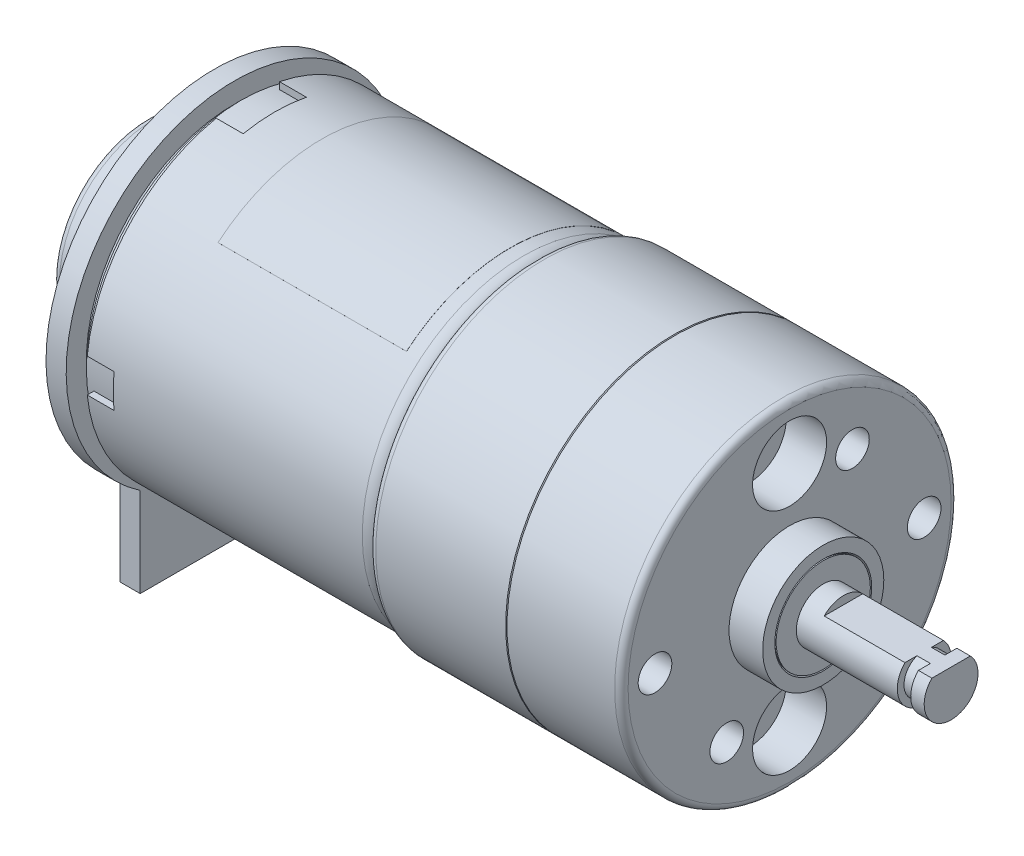
from build123d import *

# Parameters (mm, degrees)
ESQUISSE3_W                = 4.7
ESQUISSE3_H                = 3
ESQUISSE3_W_2              = 3
ESQUISSE3_H_2              = 2.5
ENL_V_MAT_EXTRU_1_DEPTH    = 2
CHANFREIN1_SIZE            = 0.5
ESQUISSE5_R                = 1.25
BOSS_EXTRU_1_DEPTH         = 1.5
ESQUISSE6_R                = 12.5
BOSS_EXTRU_2_DEPTH         = 10.25
CONG_2_R                   = 0.5
CHANFREIN2_SIZE            = 0.1
ESQUISSE7_R                = 12.5
BOSS_EXTRU_3_DEPTH         = 8.5
CONG_3_R                   = 0.5
ESQUISSE8_R                = 4.5
ESQUISSE8_R_2              = 3.5
BOSS_EXTRU_4_DEPTH         = 2.5
CHANFREIN3_SIZE            = 0.1
ESQUISSE10_R               = 3.5
ESQUISSE10_R_2             = 2
BOSS_EXTRU_6_DEPTH         = 2.5
ESQUISSE13_W               = 11.559263521
ESQUISSE13_H               = 4.088991178
ENL_V_MAT_EXTRU_2_DEPTH    = 8
ESQUISSE14_R               = 1
BOSS_EXTRU_8_DEPTH         = 7.5
ESQUISSE16_R               = 7
ESQUISSE16_R_2             = 3.5
BOSS_EXTRU_9_DEPTH         = 4
CONG_4_R                   = 0.5
ESQUISSE17_R               = 3.5
ESQUISSE17_R_2             = 1.005
BOSS_EXTRU_10_DEPTH        = 0.1
BOSS_EXTRU_10_DEPTH_BACK   = 4.1
ESQUISSE18_R               = 2.75
ENL_V_MAT_EXTRU_3_DEPTH    = 3
TROU_TARAUD_M32_AT_2_COUNT = 2
TROU_TARAUD_M32_AT_2_PITCH = 17
BOSS_EXTRU_11_DEPTH        = 14


with BuildPart() as part:
    # Esquisse1 → Révol.-Mince3 (revolve)
    with BuildSketch(Plane.XY):
        with BuildLine():
            Line((0, 0), (0, -11))
            ThreePointArc((0, -11), (-0.292893219, -11.707106781), (-1, -12))
            Line((-1, -12), (-21.5, -12))
            Line((-21.5, -12), (-21.5, -11.5))
            Line((-21.5, -11.5), (-1, -11.5))
            ThreePointArc((-1, -11.5), (-0.646446609, -11.353553391), (-0.5, -11))
            Line((-0.5, -11), (-0.5, 0))
            Line((-0.5, 0), (0, 0))
        make_face()
    revolve(axis=Axis((-41.566699443, 0, 0), (1, 0, 0)))

    # Esquisse3 → Enlèv. mat.-Extru.1 (cut)
    with BuildSketch(Plane.ZY.offset(21.5)):
        with Locations((0, -11.5)):
            Rectangle(ESQUISSE3_W, ESQUISSE3_H)
        with Locations((0, 11.5)):
            Rectangle(ESQUISSE3_W, ESQUISSE3_H)
        with Locations((11.5, 0)):
            Rectangle(ESQUISSE3_W_2, ESQUISSE3_H_2)
        with Locations((-11.5, 0)):
            Rectangle(ESQUISSE3_W_2, ESQUISSE3_H_2)
    extrude(amount=-ENL_V_MAT_EXTRU_1_DEPTH, mode=Mode.SUBTRACT)

    # Esquisse4 → Révolution2 (revolve)
    with BuildSketch(Plane.XY):
        with BuildLine():
            Line((-0.5, 11), (-0.5, 0))
            Line((-0.5, 0), (-22.5, 0))
            Line((-22.5, 0), (-22.5, 11.5))
            Line((-22.5, 11.5), (-1, 11.5))
            ThreePointArc((-1, 11.5), (-0.646446609, 11.353553391), (-0.5, 11))
        make_face()
    revolve(axis=Axis((-25.268401873, 0, 0), (1, 0, 0)))

    # Chanfrein1
    chanfrein1_edges = [part.edges().sort_by_distance(p)[0] for p in [
        (-22.5, -11.5, 0),
    ]]
    chamfer(chanfrein1_edges, length=CHANFREIN1_SIZE)

    # Esquisse5 → Boss.-Extru.1 (add)
    with BuildSketch(Plane.ZY.offset(22.5)):
        with BuildLine():
            Line((-7, -10.356157589), (-7, -17))
            Line((-7, -17), (7, -17))
            Line((7, -17), (7, -10.356157589))
            ThreePointArc((7, -10.356157589), (0, 12.5), (-7, -10.356157589))
        make_face()
        Circle(ESQUISSE5_R, mode=Mode.SUBTRACT)
    extrude(amount=BOSS_EXTRU_1_DEPTH)

    # Esquisse6 → Boss.-Extru.2 (add)
    with BuildSketch(Plane(origin=(0, 0, 0), x_dir=(0, 0, -1), z_dir=(1, 0, 0))):
        Circle(ESQUISSE6_R)
    extrude(amount=BOSS_EXTRU_2_DEPTH)

    # Congé2
    cong_2_edges = [part.edges().sort_by_distance(p)[0] for p in [
        (0, 0, 12.5),
    ]]
    fillet(cong_2_edges, radius=CONG_2_R)

    # Chanfrein2
    chanfrein2_edges = [part.edges().sort_by_distance(p)[0] for p in [
        (10.25, 0, 12.5),
    ]]
    chamfer(chanfrein2_edges, length=CHANFREIN2_SIZE)

    # Esquisse7 → Boss.-Extru.3 (add)
    with BuildSketch(Plane(origin=(10.25, 0, 0), x_dir=(0, 0, -1), z_dir=(1, 0, 0))):
        Circle(ESQUISSE7_R)
    extrude(amount=BOSS_EXTRU_3_DEPTH)

    # Congé3
    cong_3_edges = [part.edges().sort_by_distance(p)[0] for p in [
        (18.75, 0, 12.5),
    ]]
    fillet(cong_3_edges, radius=CONG_3_R)

    # Esquisse8 → Boss.-Extru.4 (add)
    with BuildSketch(Plane(origin=(18.75, 0, 0), x_dir=(0, 0, -1), z_dir=(1, 0, 0))):
        Circle(ESQUISSE8_R)
        Circle(ESQUISSE8_R_2, mode=Mode.SUBTRACT)
    extrude(amount=BOSS_EXTRU_4_DEPTH)

    # Chanfrein3
    chanfrein3_edges = [part.edges().sort_by_distance(p)[0] for p in [
        (21.25, 0, 3.5),
    ]]
    chamfer(chanfrein3_edges, length=CHANFREIN3_SIZE)

    # Esquisse10 → Boss.-Extru.6 (add)
    with BuildSketch(Plane(origin=(18.75, 0, 0), x_dir=(0, 0, -1), z_dir=(1, 0, 0))):
        Circle(ESQUISSE10_R)
        Circle(ESQUISSE10_R_2, mode=Mode.SUBTRACT)
    extrude(amount=BOSS_EXTRU_6_DEPTH)

    # Esquisse12 → Révolution3 (revolve)
    with BuildSketch(Plane.XY):
        Polygon((18.75, -2), (28.75, -2), (28.75, -1.5), (29.75, -1.5), (29.75, -2), (30.75, -2), (30.75, 0), (18.75, 0), align=None)
    revolve(axis=Axis((-4.872202699, 0, 0), (1, 0, 0)))

    # Esquisse13 → Enlèv. mat.-Extru.2 (cut)
    with BuildSketch(Plane(origin=(30.75, 0, 0), x_dir=(0, 0, -1), z_dir=(1, 0, 0))):
        with Locations((0.530782509, 3.444495589)):
            Rectangle(ESQUISSE13_W, ESQUISSE13_H)
    extrude(amount=-ENL_V_MAT_EXTRU_2_DEPTH, mode=Mode.SUBTRACT)

    # Esquisse14 → Boss.-Extru.8 (add)
    with BuildSketch(Plane.ZY.offset(22.5)):
        Circle(ESQUISSE14_R)
    extrude(amount=BOSS_EXTRU_8_DEPTH)

    # Esquisse18 → Enlèv. mat.-Extru.3 (cut)
    with BuildSketch(Plane(origin=(18.75, 0, 0), x_dir=(0, 0, -1), z_dir=(1, 0, 0))):
        with Locations((0, 8.5)):
            Circle(ESQUISSE18_R)
        with Locations((0, -8.5)):
            Circle(ESQUISSE18_R)
    extrude(amount=-ENL_V_MAT_EXTRU_3_DEPTH, mode=Mode.SUBTRACT)

    # Esquisse19 → Trou taraudé M31 (revolve, cut)
    with BuildSketch(Plane(origin=(18.75, 0, 10), x_dir=(0, 0, -1), z_dir=(0, 1, 0))):
        Polygon((0, 0), (0, 9.251075774), (1.25, 8.5), (1.25, 0), align=None)
    trou_taraud_m31 = revolve(axis=Axis((25.1, 0, 10), (-1, 0, 0)), mode=Mode.SUBTRACT)

    # Symétrie1: Trou taraudé M31 across plane
    add(trou_taraud_m31.mirror(Plane.XY), mode=Mode.SUBTRACT)

    # Esquisse24 → Trou taraudé M32 (revolve, cut)
    with BuildSketch(Plane(origin=(18.75, 7.101918123, -4.670413149), x_dir=(0, 0, -1), z_dir=(0, 1, 0))):
        Polygon((0, 0), (0, 9.251075774), (1.25, 8.5), (1.25, 0), align=None)
    trou_taraud_m32 = revolve(axis=Axis((25.1, 7.101918123, -4.670413149), (-1, 0, 0)), mode=Mode.SUBTRACT)

    # Trou taraudé M32 at 2: Trou taraudé M32 ×2
    with Locations(*[Vector(0, -0.835519779, 0.54946037) * (i * TROU_TARAUD_M32_AT_2_PITCH) for i in range(1, TROU_TARAUD_M32_AT_2_COUNT)]):
        add(trou_taraud_m32, mode=Mode.SUBTRACT)

    # Esquisse25 → Boss.-Extru.11 (add)
    with BuildSketch(Plane(origin=(-2, 0, 0), x_dir=(0, 0, -1), z_dir=(1, 0, 0))):
        with BuildLine():
            Line((7.713451316, 9.192533317), (7.719879192, 9.200193762))
            ThreePointArc((7.719879192, 9.200193762), (0, 12.01), (-7.719879192, 9.200193762))
            Line((-7.719879192, 9.200193762), (-7.713451316, 9.192533317))
            ThreePointArc((-7.713451316, 9.192533317), (0, 12), (7.713451316, 9.192533317))
        make_face()
    extrude(amount=-BOSS_EXTRU_11_DEPTH)


with BuildPart() as body_2:
    # Esquisse16 → Boss.-Extru.9 (new body)
    with BuildSketch(Plane.ZY.offset(29)):
        Circle(ESQUISSE16_R)
        Circle(ESQUISSE16_R_2, mode=Mode.SUBTRACT)
    extrude(amount=-BOSS_EXTRU_9_DEPTH)

    # Congé4
    cong_4_edges = [body_2.edges().sort_by_distance(p)[0] for p in [
        (-29, 0, -7),
        (-25, 0, -7),
    ]]
    fillet(cong_4_edges, radius=CONG_4_R)

    # Esquisse17 → Boss.-Extru.10 (add, two sides)
    with BuildSketch(Plane.ZY.offset(29)) as boss_extru_10_sk:
        Circle(ESQUISSE17_R)
        Circle(ESQUISSE17_R_2, mode=Mode.SUBTRACT)
    extrude(amount=BOSS_EXTRU_10_DEPTH)
    extrude(boss_extru_10_sk.sketch, amount=-BOSS_EXTRU_10_DEPTH_BACK)


solid = Compound([part.part, body_2.part])
